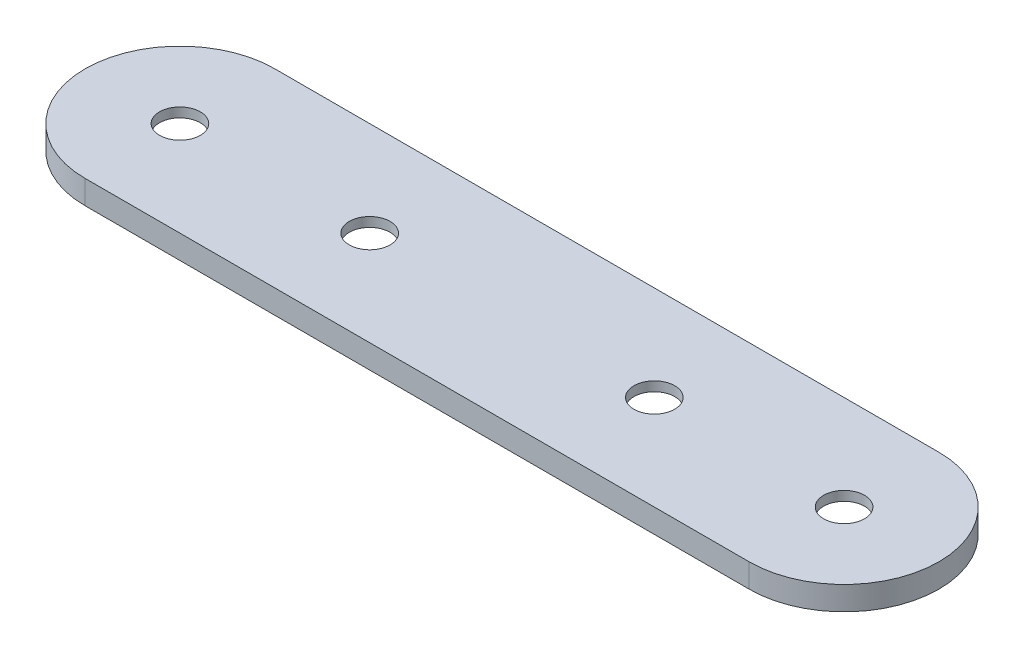
from build123d import *

# Parameters (mm, degrees)
SKETCH1_R             = 2.15
BOSS_EXTRUDE1_DEPTH   = 2.5
CHAMFER1_SIZE         = 1.5
CHAMFER1_SIZE2        = 2.598076211
CHAMFER1_PART_2_SIZE  = 1.5
CHAMFER1_PART_2_SIZE2 = 2.598076211
CHAMFER1_PART_3_SIZE  = 1.5
CHAMFER1_PART_3_SIZE2 = 2.598076211
CHAMFER1_PART_4_SIZE  = 1.5
CHAMFER1_PART_4_SIZE2 = 2.598076211


with BuildPart() as part:
    # Sketch1 → Boss-Extrude1 (new body)
    with BuildSketch(Plane(origin=(0, 0, 0), x_dir=(1, 0, 0), z_dir=(0, 1, 0))):
        with BuildLine():
            Line((0, -10), (-70, -10))
            ThreePointArc((-70, -10), (-80, 0), (-70, 10))
            Line((-70, 10), (0, 10))
            ThreePointArc((0, 10), (10, 0), (0, -10))
        make_face()
        Circle(SKETCH1_R, mode=Mode.SUBTRACT)
        with Locations((-70, 0)):
            Circle(SKETCH1_R, mode=Mode.SUBTRACT)
        with Locations((-20, 0)):
            Circle(SKETCH1_R, mode=Mode.SUBTRACT)
        with Locations((-50, 0)):
            Circle(SKETCH1_R, mode=Mode.SUBTRACT)
    extrude(amount=-BOSS_EXTRUDE1_DEPTH)

    # Chamfer1
    chamfer1_edges = [part.edges().sort_by_distance(p)[0] for p in [
        (-2.15, -2.5, 0),
    ]]
    chamfer1_side = [part.faces().sort_by_distance(p)[0] for p in [
        (-2.15, -1.25, 0),
    ]]
    chamfer(chamfer1_edges, length=CHAMFER1_SIZE, length2=CHAMFER1_SIZE2, reference=chamfer1_side[0])

    # Chamfer1 part 2
    chamfer1_part_2_edges = [part.edges().sort_by_distance(p)[0] for p in [
        (-72.15, -2.5, 0),
    ]]
    chamfer1_part_2_side = [part.faces().sort_by_distance(p)[0] for p in [
        (-72.15, -1.25, 0),
    ]]
    chamfer(chamfer1_part_2_edges, length=CHAMFER1_PART_2_SIZE, length2=CHAMFER1_PART_2_SIZE2, reference=chamfer1_part_2_side[0])

    # Chamfer1 part 3
    chamfer1_part_3_edges = [part.edges().sort_by_distance(p)[0] for p in [
        (-22.15, -2.5, 0),
    ]]
    chamfer1_part_3_side = [part.faces().sort_by_distance(p)[0] for p in [
        (-22.15, -1.25, 0),
    ]]
    chamfer(chamfer1_part_3_edges, length=CHAMFER1_PART_3_SIZE, length2=CHAMFER1_PART_3_SIZE2, reference=chamfer1_part_3_side[0])

    # Chamfer1 part 4
    chamfer1_part_4_edges = [part.edges().sort_by_distance(p)[0] for p in [
        (-52.15, -2.5, 0),
    ]]
    chamfer1_part_4_side = [part.faces().sort_by_distance(p)[0] for p in [
        (-52.15, -1.25, 0),
    ]]
    chamfer(chamfer1_part_4_edges, length=CHAMFER1_PART_4_SIZE, length2=CHAMFER1_PART_4_SIZE2, reference=chamfer1_part_4_side[0])


solid = part.part
